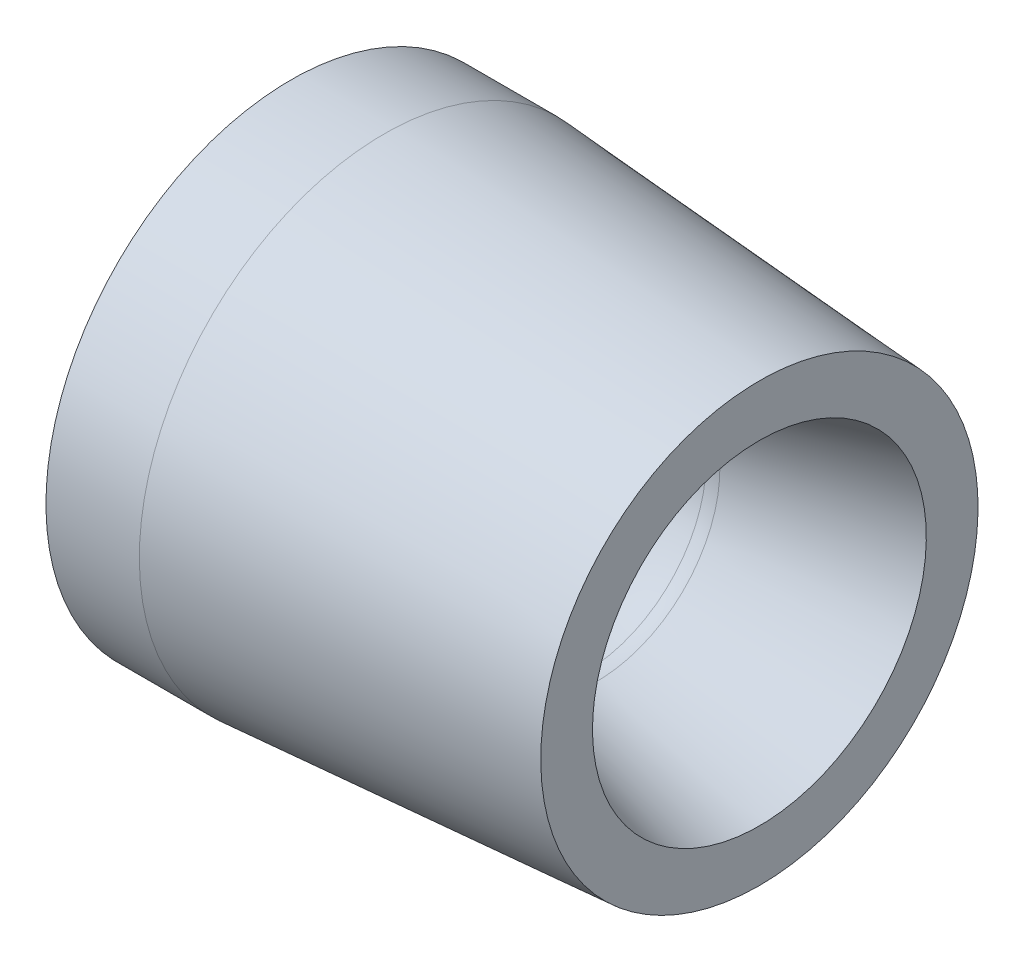
from build123d import *


with BuildPart() as part:
    # Sketch1 → Revolve1 (revolve)
    with BuildSketch(Plane.XY):
        with BuildLine():
            ThreePointArc((-9.310840107, 19.331058169), (-4.730423414, 18.075866931), (0, 17.653))
            ThreePointArc((0, 17.653), (0.898160183, 17.712068298), (1.780848569, 17.888255676))
            Line((1.780848569, 17.888255676), (90.17, 41.656))
            Line((90.17, 41.656), (-59.69, 38.1))
            Line((-59.69, 38.1), (-9.310840107, 19.331058169))
        make_face()
    revolve(axis=Axis((0, 0, 0), (-1, 0, 0)))

    # Sketch2 → Cut-Revolve1 (revolve, cut)
    with BuildSketch(Plane.XY):
        Polygon((-29.085538438, 35.56), (25.4, 31.75), (25.4, 0), (94.515783367, 0), (94.515783367, 51.74538216), (-80.408492958, 51.74538216), (-80.408492958, 0), (-50.8, 0), (-50.8, 31.75), (-42.645476755, 31.75), (-42.645476755, 35.56), align=None)
    revolve(axis=Axis((-50.8, 0, 0), (1, 0, 0)), mode=Mode.SUBTRACT)


solid = part.part
